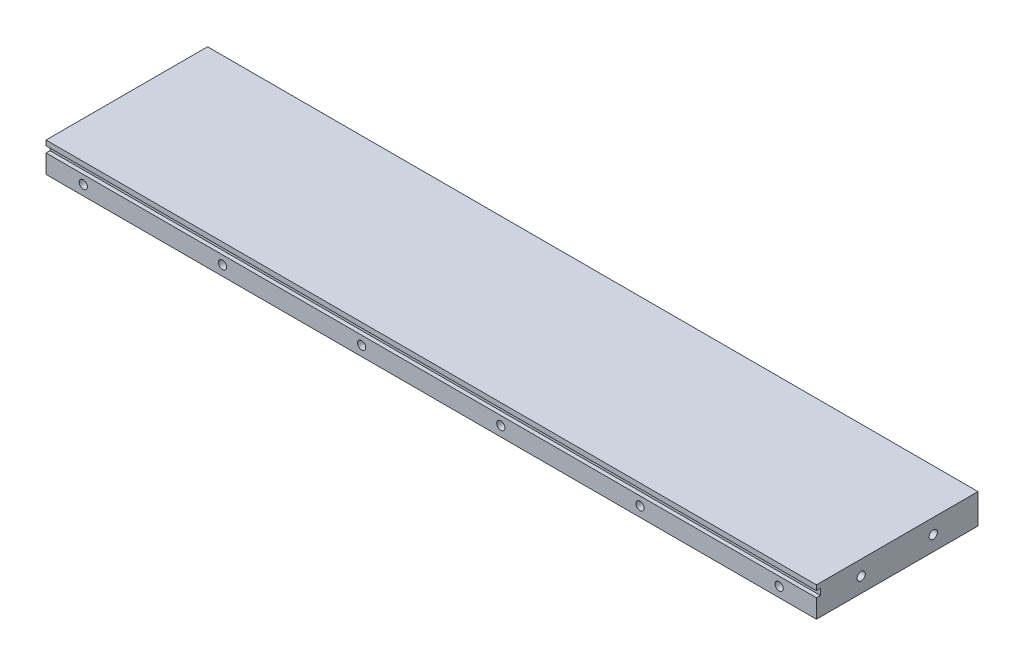
from build123d import *

# Parameters (mm, degrees)
SKIZZE1_W                       = 310
SKIZZE1_H                       = 12
AUFSATZ_LINEAR_AUSTRAGEN1_DEPTH = 65
SKIZZE2_W                       = 310
SKIZZE2_H                       = 2.5
SCHNITT_LINEAR_AUSTRAGEN1_DEPTH = 1.6
M4_GEWINDEBOHRUNG1_D            = 3.3
M4_GEWINDEBOHRUNG1_DEPTH        = 11.5
M4_GEWINDEBOHRUNG1_TIP          = 0.991420021
M4_GEWINDEBOHRUNG2_AT_2_COUNT   = 2
M4_GEWINDEBOHRUNG2_AT_2_PITCH   = 29


with BuildPart() as part:
    # Skizze1 → Aufsatz-Linear austragen1 (new body)
    with BuildSketch(Plane.XY):
        with Locations((155, 6)):
            Rectangle(SKIZZE1_W, SKIZZE1_H)
    extrude(amount=-AUFSATZ_LINEAR_AUSTRAGEN1_DEPTH)

    # Skizze2 → Schnitt-Linear austragen1 (cut)
    with BuildSketch(Plane.XY):
        with Locations((155, 8.75)):
            Rectangle(SKIZZE2_W, SKIZZE2_H)
    extrude(amount=-SCHNITT_LINEAR_AUSTRAGEN1_DEPTH, mode=Mode.SUBTRACT)

    # M4 Gewindebohrung1
    with Locations(Plane(origin=(295, 4, 0), x_dir=(1, 0, 0), z_dir=(0, 0, 1))):
        with Locations((0, 0), (-280, 0), (-224, 0), (-168, 0), (-112, 0), (-56, 0)):
            Hole(M4_GEWINDEBOHRUNG1_D / 2, depth=M4_GEWINDEBOHRUNG1_DEPTH)
            with Locations((0, 0, -(M4_GEWINDEBOHRUNG1_DEPTH + M4_GEWINDEBOHRUNG1_TIP / 2))):  # 118° drill point
                Cone(0, M4_GEWINDEBOHRUNG1_D / 2, M4_GEWINDEBOHRUNG1_TIP, mode=Mode.SUBTRACT)

    # Skizze4 → M4 Gewindebohrung2 (revolve, cut)
    with BuildSketch(Plane(origin=(0, 6, -18), x_dir=(0, 0, 1), z_dir=(0, 1, 0))):
        Polygon((0, 0), (0, 12.491420021), (1.65, 11.5), (1.65, 0), align=None)
    m4_gewindebohrung2 = revolve(axis=Axis((-6.35, 6, -18), (1, 0, 0)), mode=Mode.SUBTRACT)

    # M4 Gewindebohrung2 at 2: M4 Gewindebohrung2 ×2
    with Locations(*[(0, 0, -i * M4_GEWINDEBOHRUNG2_AT_2_PITCH) for i in range(1, M4_GEWINDEBOHRUNG2_AT_2_COUNT)]):
        add(m4_gewindebohrung2, mode=Mode.SUBTRACT)

    # Spiegeln2: M4 Gewindebohrung2 across plane
    add(m4_gewindebohrung2.mirror(Plane(origin=(155, 0, 0), x_dir=(0, 0, 1), z_dir=(1, 0, 0))), mode=Mode.SUBTRACT)

    # Spiegeln2 copy 1 sketch → Spiegeln2 copy 1 (revolve, cut)
    with BuildSketch(Plane(origin=(310, 6, -47), x_dir=(0, 0, 1), z_dir=(0, 1, 0))):
        Polygon((0, 0), (0, -12.491420021), (1.65, -11.5), (1.65, 0), align=None)
    revolve(axis=Axis((316.35, 6, -47), (1, 0, 0)), mode=Mode.SUBTRACT)


solid = part.part
